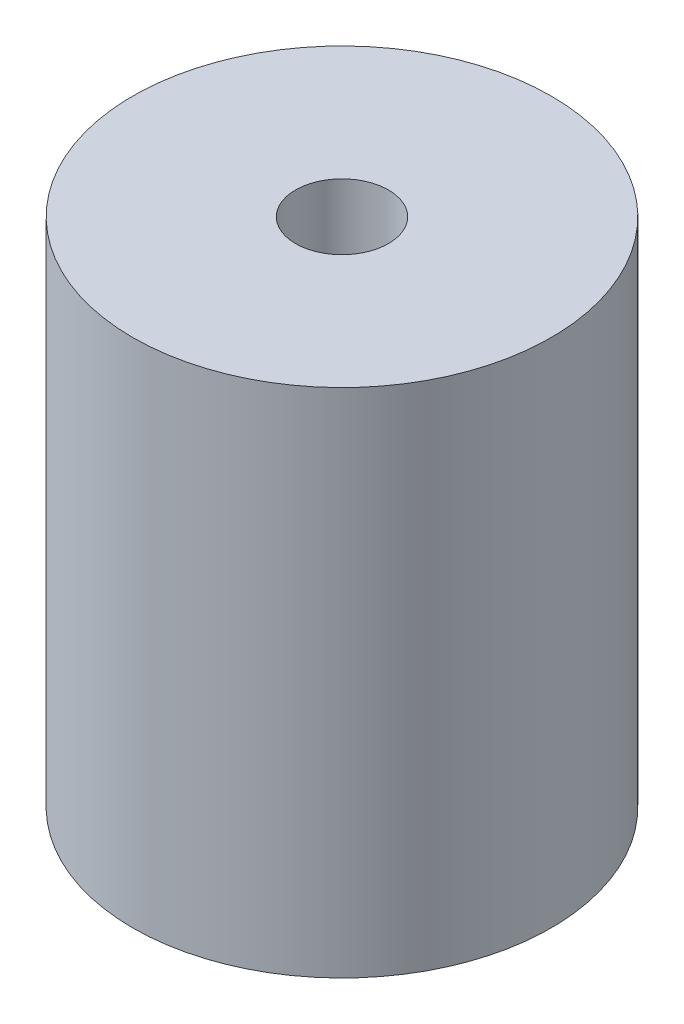
from build123d import *

# Parameters (mm, degrees)
SKETCH1_R           = 22.5
BOSS_EXTRUDE1_DEPTH = 55
SKETCH2_R           = 5
CUT_EXTRUDE1_DEPTH  = 10
SKETCH3_R           = 5
CUT_EXTRUDE2_DEPTH  = 10


with BuildPart() as part:
    # Sketch1 → Boss-Extrude1 (new body)
    with BuildSketch(Plane(origin=(0, 0, 0), x_dir=(1, 0, 0), z_dir=(0, 1, 0))):
        Circle(SKETCH1_R)
    extrude(amount=BOSS_EXTRUDE1_DEPTH)

    # Sketch2 → Cut-Extrude1 (cut)
    with BuildSketch(Plane(origin=(0, 55, 0), x_dir=(1, 0, 0), z_dir=(0, 1, 0))):
        Circle(SKETCH2_R)
    extrude(amount=-CUT_EXTRUDE1_DEPTH, mode=Mode.SUBTRACT)

    # Sketch3 → Cut-Extrude2 (cut)
    with BuildSketch(Plane.XZ):
        Circle(SKETCH3_R)
    extrude(amount=-CUT_EXTRUDE2_DEPTH, mode=Mode.SUBTRACT)


solid = part.part
